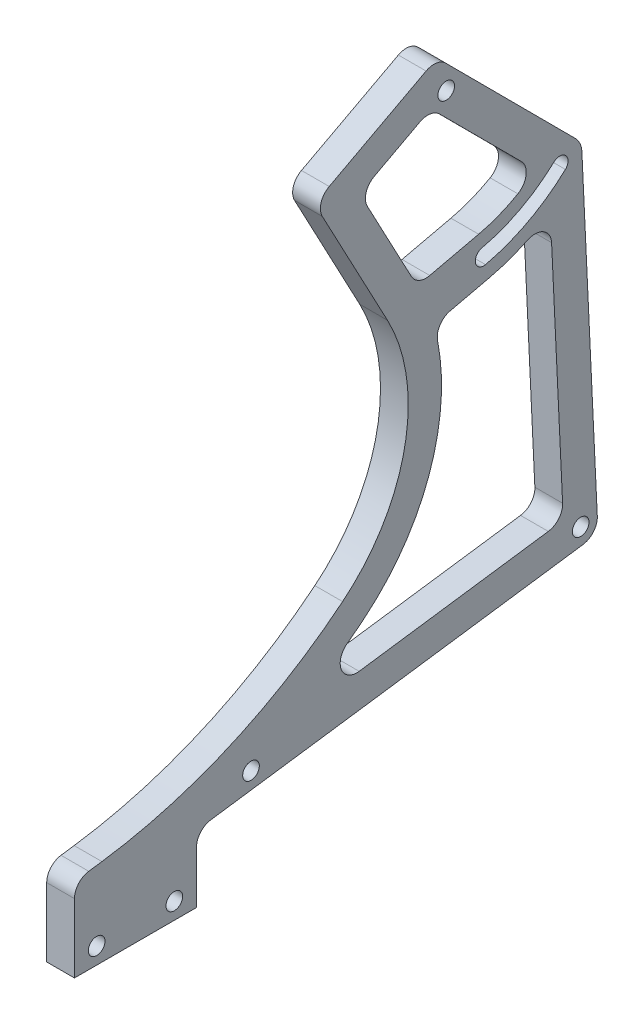
from build123d import *

# Parameters (mm, degrees)
SKETCH1_R           = 1.5
BOSS_EXTRUDE1_DEPTH = 5
FILLET1_R           = 3
CUT_EXTRUDE2_REACH  = 7
SKETCH7_R           = 1.5


with BuildPart() as part:
    # Sketch1 → Boss-Extrude1 (new body)
    with BuildSketch(Plane(origin=(0, 0, 0), x_dir=(0, 0, -1), z_dir=(1, 0, 0))):
        with BuildLine():
            Line((0, 0), (0, 15))
            Line((0, 15), (4.951340344, 15.695865505))
            ThreePointArc((4.951340344, 15.695865505), (27.926864621, 22.182944056), (48.325875811, 34.586058439))
            ThreePointArc((48.325875811, 34.586058439), (59.519665724, 53.069681974), (56.412643103, 74.454061366))
            Line((56.412643103, 74.454061366), (43.267439345, 99.176593966))
            Line((43.267439345, 99.176593966), (65.341129166, 110.913383036))
            Line((65.341129166, 110.913383036), (90.292806812, 85.883380245))
            ThreePointArc((90.292806812, 85.883380245), (91.119279883, 84.674725039), (91.455424552, 83.249624372))
            Line((91.455424552, 83.249624372), (94.07546653, 28.221444591))
            Line((94.07546653, 28.221444591), (94.36203286, 22.202753427))
            Line((94.36203286, 22.202753427), (22, 12.032932928))
            Line((22, 12.032932928), (22, 0))
            Line((22, 0), (0, 0))
        make_face()
        with Locations((4, 3)):
            Circle(SKETCH1_R, mode=Mode.SUBTRACT)
        with Locations((18, 3)):
            Circle(SKETCH1_R, mode=Mode.SUBTRACT)
        with Locations((67, 105)):
            Circle(SKETCH1_R, mode=Mode.SUBTRACT)
        with BuildLine():
            Line((37.734060935, 20.303176421), (88.108596969, 27.382855762))
            Line((88.108596969, 27.382855762), (85.763043155, 76.646019476))
            ThreePointArc((85.763043155, 76.646019476), (80.419740702, 73.76043279), (74.648335848, 71.871417797))
            Line((74.648335848, 71.871417797), (64.774649495, 69.591897689))
            ThreePointArc((64.774649495, 69.591897689), (64.35710923, 47.870362906), (52.107292501, 29.927637267))
            ThreePointArc((52.107292501, 29.927637267), (45.141760841, 24.785238396), (37.734060935, 20.303176421))
        make_face(mode=Mode.SUBTRACT)
        with BuildLine():
            Line((83.108700039, 84.591428686), (64.231449963, 103.527935833))
            Line((64.231449963, 103.527935833), (51.381954278, 96.695737786))
            Line((51.381954278, 96.695737786), (61.793684809, 77.114120627))
            Line((61.793684809, 77.114120627), (72.848727413, 79.666378316))
            ThreePointArc((72.848727413, 79.666378316), (78.251497028, 81.560635362), (83.108700039, 84.591428686))
        make_face(mode=Mode.SUBTRACT)
        with BuildLine():
            ThreePointArc((74.085958212, 74.307342959), (81.788354228, 77.187150825), (88.482948342, 81.962358399))
            ThreePointArc((88.482948342, 81.962358399), (88.556981354, 84.082386492), (86.436953262, 84.156419504))
            ThreePointArc((86.436953262, 84.156419504), (80.379939539, 79.835993604), (73.411105049, 77.230453154))
            ThreePointArc((73.411105049, 77.230453154), (72.286976533, 75.431471475), (74.085958212, 74.307342959))
        make_face(mode=Mode.SUBTRACT)
    extrude(amount=BOSS_EXTRUDE1_DEPTH)

    # Fillet1
    fillet1_edges = [part.edges().sort_by_distance(p)[0] for p in [
        (2.5, 15, 0),
        (2.5, 99.176593966, -43.267439345),
        (2.5, 110.913383036, -65.341129166),
        (2.5, 22.202753427, -94.36203286),
        (2.5, 12.032932928, -22),
        (2.5, 20.303176421, -37.734060935),
        (2.5, 27.382855762, -88.108596969),
        (2.5, 76.646019476, -85.763043155),
        (2.5, 69.591897689, -64.774649495),
        (2.5, 84.591428686, -83.108700039),
        (2.5, 103.527935833, -64.231449963),
        (2.5, 96.695737786, -51.381954278),
        (2.5, 77.114120627, -61.793684809),
    ]]
    fillet(fillet1_edges, radius=FILLET1_R)

    # Sketch7 → Cut-Extrude2 (cut, up to next)
    with BuildSketch(Plane(origin=(5, 0, 0), x_dir=(0, 0, -1), z_dir=(1, 0, 0)), mode=Mode.PRIVATE) as cut_extrude2_sk1:
        with Locations((31.81923079, 16.442418537)):
            Circle(SKETCH7_R)
    cut_extrude2_tool1 = extrude(cut_extrude2_sk1.sketch, amount=-CUT_EXTRUDE2_REACH, mode=Mode.PRIVATE) & part.part
    add(cut_extrude2_tool1.solids().sort_by_distance((5, 16.442419, -31.819231))[0], mode=Mode.SUBTRACT)
    # Sketch7 → Cut-Extrude2 (cut, up to next)
    with BuildSketch(Plane(origin=(5, 0, 0), x_dir=(0, 0, -1), z_dir=(1, 0, 0)), mode=Mode.PRIVATE) as cut_extrude2_sk2:
        with Locations((91.235314915, 24.792804595)):
            Circle(SKETCH7_R)
    cut_extrude2_tool2 = extrude(cut_extrude2_sk2.sketch, amount=-CUT_EXTRUDE2_REACH, mode=Mode.PRIVATE) & part.part
    add(cut_extrude2_tool2.solids().sort_by_distance((5, 24.792805, -91.235315))[0], mode=Mode.SUBTRACT)


solid = part.part
